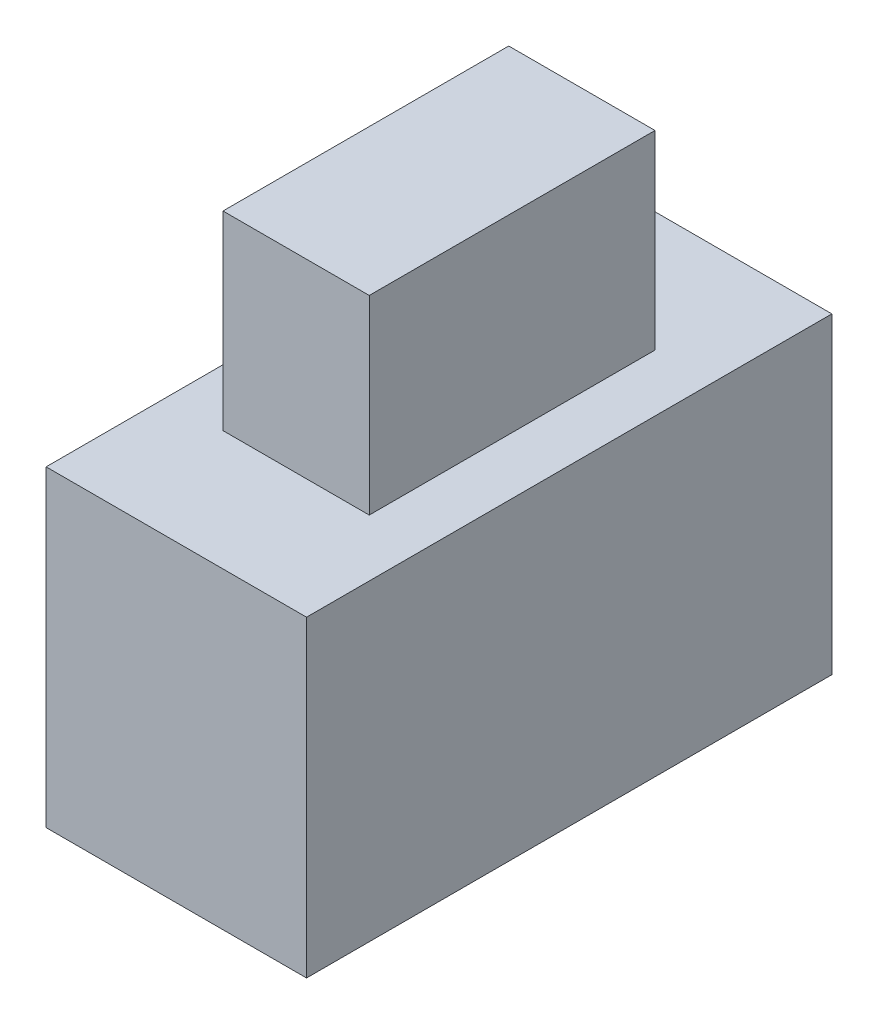
from build123d import *

# Parameters (mm, degrees)
SWITCH_BASE_SKETCH_W      = 5.75
SWITCH_BASE_SKETCH_H      = 11.6
SWITCH_BASE_EXTRUDE_DEPTH = 6.9
PULLSWITCH_SKETCH_W       = 3.23
PULLSWITCH_SKETCH_H       = 6.31
PULLSWITCH_EXTRUDE_DEPTH  = 4.2


with BuildPart() as part:
    # Switch Base Sketch → Switch Base Extrude (new body)
    with BuildSketch(Plane(origin=(0, 0, 0), x_dir=(1, 0, 0), z_dir=(0, 1, 0))):
        with Locations((2.875, 5.8)):
            Rectangle(SWITCH_BASE_SKETCH_W, SWITCH_BASE_SKETCH_H)
    extrude(amount=SWITCH_BASE_EXTRUDE_DEPTH)

    # PullSwitch Sketch → PullSwitch Extrude (add)
    with BuildSketch(Plane(origin=(0, 6.9, 0), x_dir=(1, 0, 0), z_dir=(0, 1, 0))):
        with Locations((2.875, 5.8)):
            Rectangle(PULLSWITCH_SKETCH_W, PULLSWITCH_SKETCH_H)
    extrude(amount=PULLSWITCH_EXTRUDE_DEPTH)


solid = part.part
